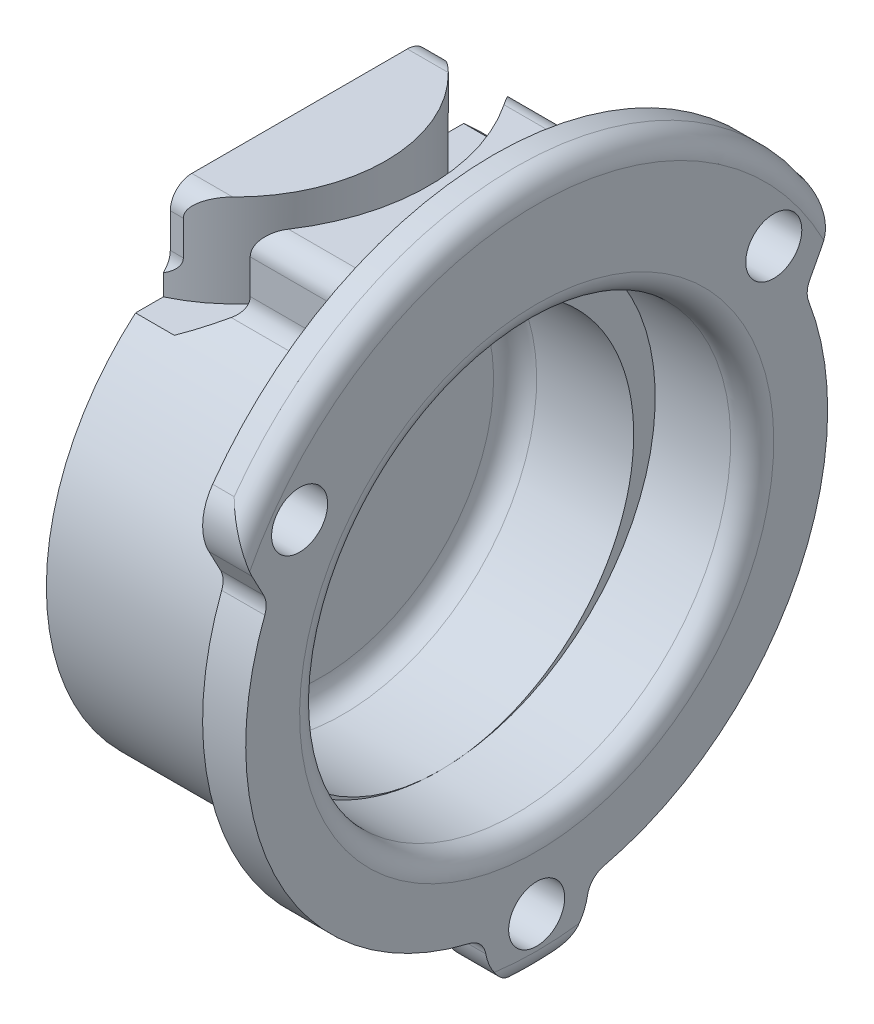
from build123d import *

# Parameters (mm, degrees)
SKETCH2_OUTSIDE_W  = 43.314
SKETCH2_OUTSIDE_H  = 43.314
CUT_EXTRUDE1_DEPTH = 10
SKETCH3_R          = 1.3
CUT_EXTRUDE2_DEPTH = 3
SKETCH5_R          = 9
SKETCH5_R_2        = 7
CUT_EXTRUDE3_DEPTH = 4.3


with BuildPart() as part:
    # Sketch1 → Revolve1 (revolve)
    with BuildSketch(Plane.XY):
        with BuildLine():
            Line((-2.5, 10), (-2.5, 0))
            Line((-2.5, 0), (-9, 0))
            Line((-9, 0), (-9, 16))
            Line((-9, 16), (1, 16))
            ThreePointArc((1, 16), (1.707106781, 15.707106781), (2, 15))
            Line((2, 15), (2, 11))
            ThreePointArc((2, 11), (1.707106781, 10.292893219), (1, 10))
            Line((1, 10), (-2.5, 10))
        make_face()
    revolve(axis=Axis((0, 0, 0), (-1, 0, 0)))

    # Sketch2 outside → Cut-Extrude1 (cut, through all)
    with BuildSketch(Plane(origin=(0, 0, 0), x_dir=(0, 0, -1), z_dir=(1, 0, 0))):
        Rectangle(SKETCH2_OUTSIDE_W, SKETCH2_OUTSIDE_H)
        with BuildLine():
            Line((5, 13.25), (-5, 13.25))
            ThreePointArc((-5, 13.25), (-5.707106781, 12.957106781), (-6, 12.25))
            Line((-6, 12.25), (-6, 10.656570743))
            ThreePointArc((-6, 10.656570743), (-6.119937614, 10.181712663), (-6.450980392, 9.820761273))
            ThreePointArc((-6.450980392, 9.820761273), (0, -11.75), (6.450980392, 9.820761273))
            ThreePointArc((6.450980392, 9.820761273), (6.119937614, 10.181712663), (6, 10.656570743))
            Line((6, 10.656570743), (6, 12.25))
            ThreePointArc((6, 12.25), (5.707106781, 12.957106781), (5, 13.25))
        make_face(mode=Mode.SUBTRACT)
    extrude(amount=-CUT_EXTRUDE1_DEPTH, mode=Mode.SUBTRACT)

    # Sketch3 → Cut-Extrude2 (cut, through all)
    with BuildSketch(Plane(origin=(0, 0, 0), x_dir=(0, 0, -1), z_dir=(1, 0, 0))):
        with Locations((-11, 7.829080757)):
            Circle(SKETCH3_R)
        with Locations((11, 7.829080757)):
            Circle(SKETCH3_R)
        with Locations((0, -13.501648251)):
            Circle(SKETCH3_R)
        with BuildLine():
            Line((-12.664898978, 5.629114116), (-13.210413813, 6.664678663))
            ThreePointArc((-13.210413813, 6.664678663), (-13.492769962, 7.995992047), (-13.035445505, 9.277777778))
            ThreePointArc((-13.035445505, 9.277777778), (0, -16), (13.035445505, 9.277777778))
            ThreePointArc((13.035445505, 9.277777778), (13.492769962, 7.995992047), (13.210413813, 6.664678663))
            Line((13.210413813, 6.664678663), (12.664898978, 5.629114116))
            ThreePointArc((12.664898978, 5.629114116), (12.551470751, 5.223399463), (12.615189348, 4.806973861))
            ThreePointArc((12.615189348, 4.806973861), (11.930739874, -6.317234051), (3.114633748, -13.135792957))
            ThreePointArc((3.114633748, -13.135792957), (2.619659949, -13.420790107), (2.361421665, -13.930236303))
            ThreePointArc((2.361421665, -13.930236303), (0, -15.901648251), (-2.361421665, -13.930236303))
            ThreePointArc((-2.361421665, -13.930236303), (-2.619659949, -13.420790107), (-3.114633748, -13.135792957))
            ThreePointArc((-3.114633748, -13.135792957), (-11.930739874, -6.317234051), (-12.615189348, 4.806973861))
            ThreePointArc((-12.615189348, 4.806973861), (-12.551470751, 5.223399463), (-12.664898978, 5.629114116))
        make_face()
    extrude(amount=CUT_EXTRUDE2_DEPTH, mode=Mode.SUBTRACT)

    # Sketch4 → Cut-Revolve1 (revolve, cut)
    with BuildSketch(Plane.XY, mode=Mode.PRIVATE) as cut_revolve1_sk:
        with BuildLine():
            Line((-2.5, -1), (-8, -1))
            Line((-8, -1), (-8, -9))
            ThreePointArc((-8, -9), (-7.707106781, -9.707106781), (-7, -10))
            Line((-7, -10), (-2.5, -10))
            Line((-2.5, -10), (-2.5, -1))
        make_face()
    revolve(cut_revolve1_sk.sketch.rotate(Axis((2, -1, 0), (-1, 0, 0)), 180), axis=Axis((2, -1, 0), (-1, 0, 0)), mode=Mode.SUBTRACT)  # turned: the seam where the file's is

    # Sketch5 → Cut-Extrude3 (cut)
    with BuildSketch(Plane(origin=(0, 13.25, 0), x_dir=(-1, 0, 0), z_dir=(0, 1, 0))):
        with Locations((12, 0)):
            Circle(SKETCH5_R)
        with Locations((12, 0)):
            Circle(SKETCH5_R_2, mode=Mode.SUBTRACT)
    extrude(amount=-CUT_EXTRUDE3_DEPTH, mode=Mode.SUBTRACT)


solid = part.part
